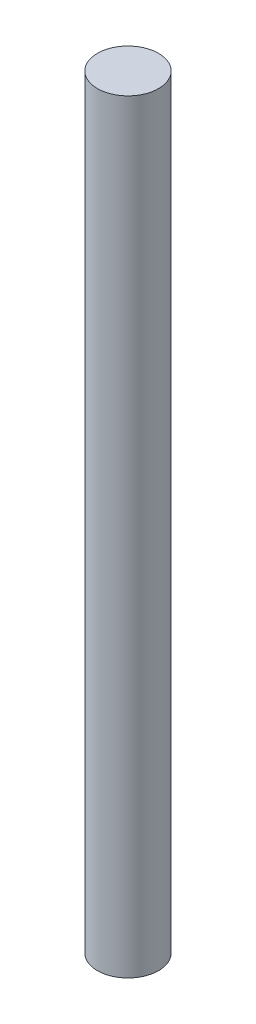
from build123d import *

# Parameters (mm, degrees)
SKETCH1_R           = 1.6
BOSS_EXTRUDE1_DEPTH = 40


with BuildPart() as part:
    # Sketch1 → Boss-Extrude1 (new body)
    with BuildSketch(Plane(origin=(0, 0, 0), x_dir=(1, 0, 0), z_dir=(0, 1, 0))):
        Circle(SKETCH1_R)
    extrude(amount=BOSS_EXTRUDE1_DEPTH)


solid = part.part
